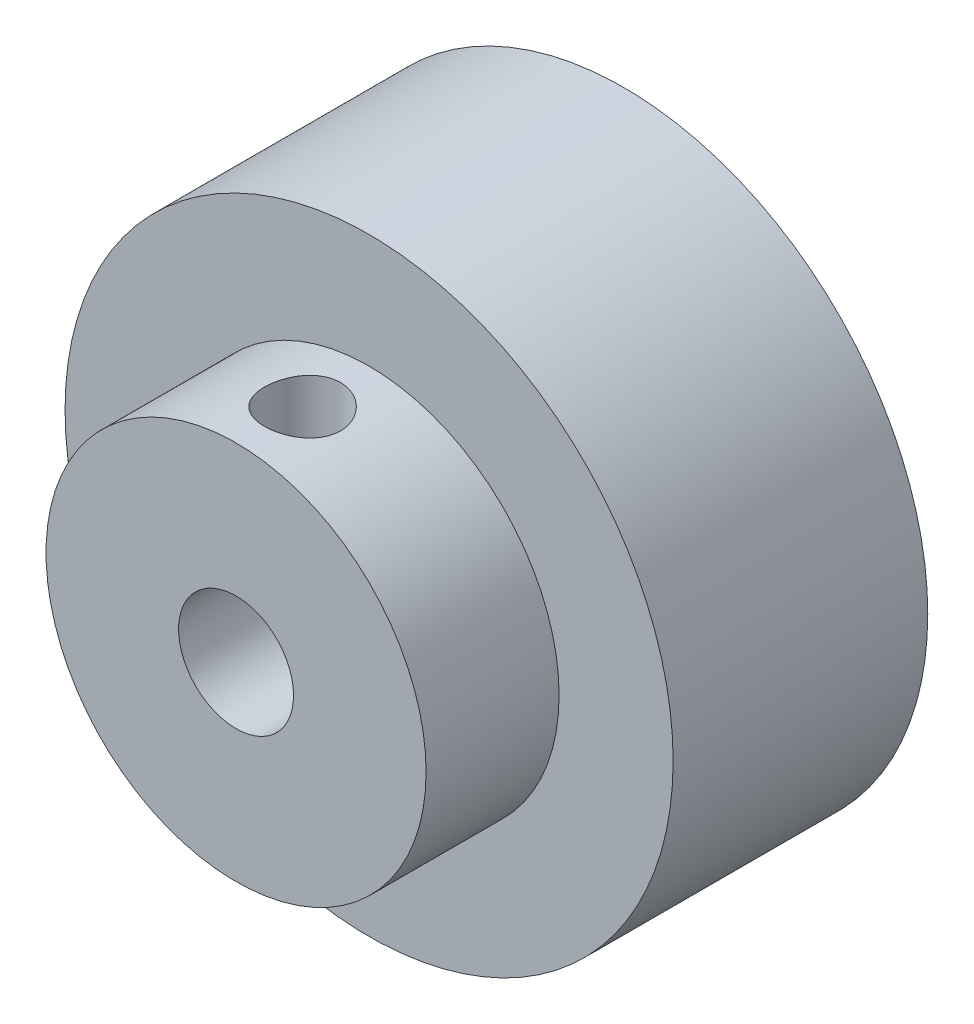
from build123d import *

# Parameters (mm, degrees)
ESQUISSE1_R             = 16
ESQUISSE1_R_2           = 3.1
BOSS_EXTRU_1_DEPTH      = 6.7
ESQUISSE2_R             = 13.660407535
ESQUISSE2_R_2           = 7.85
ENL_V_MAT_EXTRU_1_DEPTH = 5.15
ESQUISSE4_R             = 10
ESQUISSE4_R_2           = 3.025
BOSS_EXTRU_2_DEPTH      = 7
ESQUISSE5_R             = 2
ENL_V_MAT_EXTRU_3_DEPTH = 17


with BuildPart() as part:
    # Esquisse1 → Boss.-Extru.1 (new body, symmetric)
    with BuildSketch(Plane.XY):
        Circle(ESQUISSE1_R)
        Circle(ESQUISSE1_R_2, mode=Mode.SUBTRACT)
    extrude(amount=BOSS_EXTRU_1_DEPTH, both=True)

    # Esquisse2 → Enlèv. mat.-Extru.1 (cut, symmetric)
    with BuildSketch(Plane.XY):
        Circle(ESQUISSE2_R)
        Circle(ESQUISSE2_R_2, mode=Mode.SUBTRACT)
    extrude(amount=ENL_V_MAT_EXTRU_1_DEPTH, both=True, mode=Mode.SUBTRACT)

    # Esquisse4 → Boss.-Extru.2 (add)
    with BuildSketch(Plane.XY.offset(6.7)):
        Circle(ESQUISSE4_R)
        Circle(ESQUISSE4_R_2, mode=Mode.SUBTRACT)
    extrude(amount=BOSS_EXTRU_2_DEPTH)

    # Esquisse5 → Enlèv. mat.-Extru.3 (cut, through all)
    with BuildSketch(Plane(origin=(0, 0, 0), x_dir=(1, 0, 0), z_dir=(0, 1, 0))):
        with Locations((0, -10.2)):
            Circle(ESQUISSE5_R)
    extrude(amount=ENL_V_MAT_EXTRU_3_DEPTH, mode=Mode.SUBTRACT)


solid = part.part
